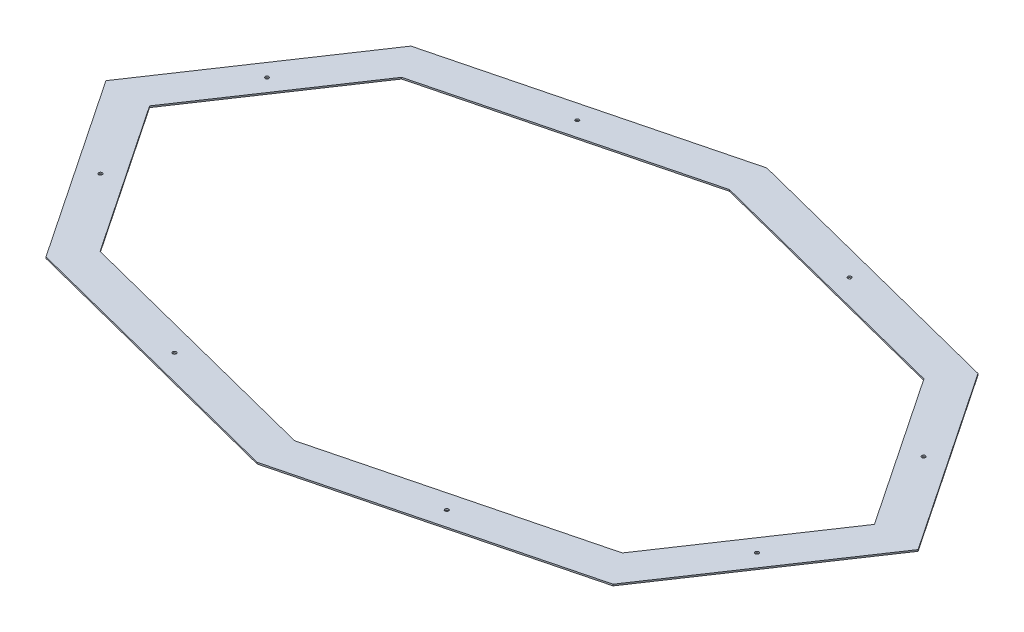
from build123d import *

# Parameters (mm, degrees)
BOSS_EXTRUDE1_DEPTH     = 1.5875
SKETCH3_R               = 3.81
CUT_EXTRUDE1_DEPTH      = 2.5875
CUT_EXTRUDE1_DEPTH_BACK = 2.5875


with BuildPart() as part:
    # Sketch2 → Boss-Extrude1 (new body, symmetric)
    with BuildSketch(Plane(origin=(0, 0, 0), x_dir=(1, 0, 0), z_dir=(0, 1, 0))):
        Polygon((-596.116107134, 383.646334781), (0, 535.844392641), (596.116107134, 383.646334781), (853.792184287, 0), (596.116107134, -383.646334781), (0, -535.844392641), (-596.116107134, -383.646334781), (-853.792184287, 0), align=None)
        Polygon((-762, 0), (-549.079439398, 317.011162143), (0, 457.2), (549.079439398, 317.011162143), (762, 0), (549.079439398, -317.011162143), (0, -457.2), (-549.079439398, -317.011162143), align=None, mode=Mode.SUBTRACT)
    extrude(amount=BOSS_EXTRUDE1_DEPTH, both=True)

    # Sketch3 → Cut-Extrude1 (cut, two sides)
    with BuildSketch(Plane(origin=(0, 0, 0), x_dir=(1, 0, 0), z_dir=(0, 1, 0))) as cut_extrude1_sk:
        with Locations((690.246932705, 175.164374231)):
            Circle(SKETCH3_R)
        with Locations((690.246932705, -175.164374231)):
            Circle(SKETCH3_R)
        with Locations((-690.246932705, -175.164374231)):
            Circle(SKETCH3_R)
        with Locations((-690.246932705, 175.164374231)):
            Circle(SKETCH3_R)
        with Locations((-286.298886633, 423.425472391)):
            Circle(SKETCH3_R)
        with Locations((286.298886633, 423.425472391)):
            Circle(SKETCH3_R)
        with Locations((286.298886633, -423.425472391)):
            Circle(SKETCH3_R)
        with Locations((-286.298886633, -423.425472391)):
            Circle(SKETCH3_R)
    extrude(amount=CUT_EXTRUDE1_DEPTH, mode=Mode.SUBTRACT)
    extrude(cut_extrude1_sk.sketch, amount=-CUT_EXTRUDE1_DEPTH_BACK, mode=Mode.SUBTRACT)


solid = part.part
